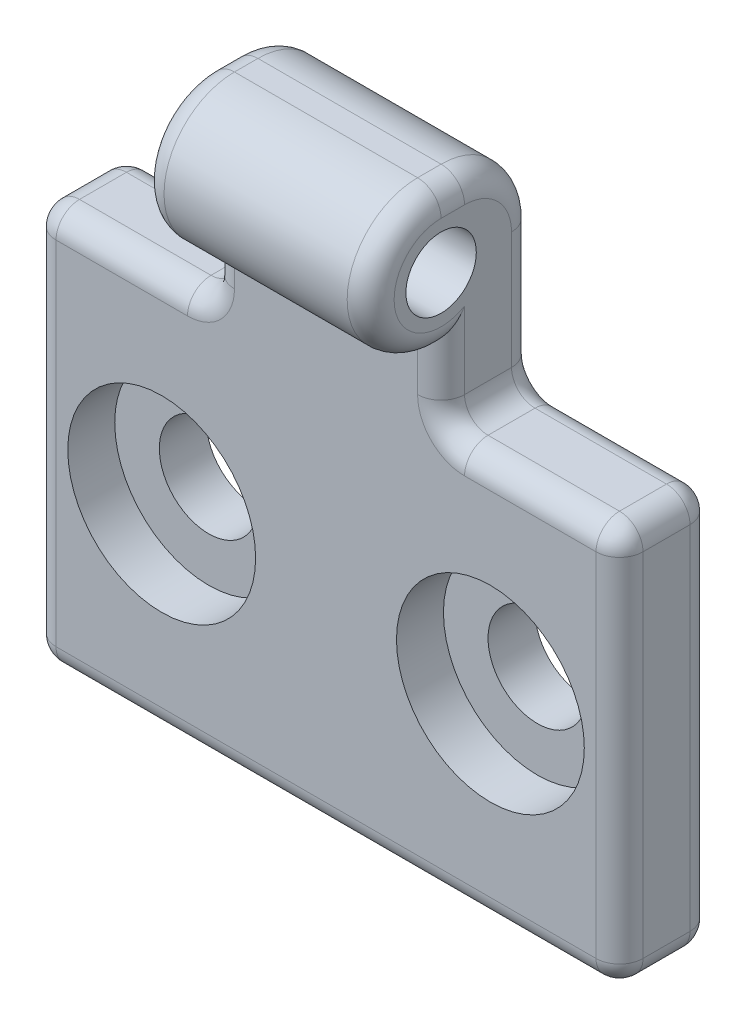
from build123d import *

# Parameters (mm, degrees)
ESQUISSE1_W                                       = 25
ESQUISSE1_H                                       = 26
BOSS_EXTRU_1_DEPTH                                = 4
BOSS_EXTRU_2_DEPTH                                = 25
ESQUISSE3_R                                       = 1.5
ENL_V_MAT_EXTRU_1_DEPTH                           = 25
ENL_V_MAT_EXTRU_2_DEPTH                           = 25
ENL_V_MAT_EXTRU_2_DEPTH_BACK                      = 25
ESQUISSE4_W                                       = 7.6
ESQUISSE4_H                                       = 9
CHAMBRAGE_POUR_VIS_SIX_PANS_CREUX_M41_D           = 4.2
CHAMBRAGE_POUR_VIS_SIX_PANS_CREUX_M41_CBORE_D     = 8
CHAMBRAGE_POUR_VIS_SIX_PANS_CREUX_M41_CBORE_DEPTH = 2
CONG_1_R                                          = 1


with BuildPart() as part:
    # Esquisse1 → Boss.-Extru.1 (new body)
    with BuildSketch(Plane.XY):
        with Locations((12.5, 13)):
            Rectangle(ESQUISSE1_W, ESQUISSE1_H)
    extrude(amount=BOSS_EXTRU_1_DEPTH)

    # Esquisse2 → Boss.-Extru.2 (add)
    with BuildSketch(Plane(origin=(25, 0, 0), x_dir=(0, 0, -1), z_dir=(1, 0, 0))):
        with BuildLine():
            Line((-4, 20), (-4, 26))
            ThreePointArc((-4, 26), (-7, 23), (-4, 20))
        make_face()
    extrude(amount=-BOSS_EXTRU_2_DEPTH)

    # Esquisse3 → Enlèv. mat.-Extru.1 (cut)
    with BuildSketch(Plane(origin=(25, 0, 0), x_dir=(0, 0, -1), z_dir=(1, 0, 0))):
        with BuildLine():
            ThreePointArc((-3, 26), (-0.878679656, 25.121320344), (0, 23))
            Line((0, 23), (0, 26))
            Line((0, 26), (-3, 26))
        make_face()
        with Locations((-4, 23)):
            Circle(ESQUISSE3_R)
    extrude(amount=-ENL_V_MAT_EXTRU_1_DEPTH, mode=Mode.SUBTRACT)

    # Esquisse4 → Enlèv. mat.-Extru.2 (cut, two sides: drawn at the far end of the back side and taken through both)
    with BuildSketch(Plane.XY.offset(4).offset(-ENL_V_MAT_EXTRU_2_DEPTH_BACK)):
        with Locations((3.8, 21.5)):
            Rectangle(ESQUISSE4_W, ESQUISSE4_H)
        with Locations((21.2, 21.5)):
            Rectangle(ESQUISSE4_W, ESQUISSE4_H)
    extrude(amount=ENL_V_MAT_EXTRU_2_DEPTH + ENL_V_MAT_EXTRU_2_DEPTH_BACK, mode=Mode.SUBTRACT)

    # Chambrage pour vis à six pans creux M41 (through all)
    with Locations(Plane(origin=(5.5, 8.51504076, 4), x_dir=(1, 0, 0), z_dir=(0, 0, 1))):
        with Locations((0, 0), (14, 0)):
            CounterBoreHole(CHAMBRAGE_POUR_VIS_SIX_PANS_CREUX_M41_D / 2, CHAMBRAGE_POUR_VIS_SIX_PANS_CREUX_M41_CBORE_D / 2, CHAMBRAGE_POUR_VIS_SIX_PANS_CREUX_M41_CBORE_DEPTH)

    # Congé1
    cong_1_edges = [part.edges().sort_by_distance(p)[0] for p in [
        (7.6, 23, 7),
        (7.6, 26, 3.5),
        (7.6, 25.121320344, 0.878679656),
        (7.6, 20, 0),
        (7.6, 18.5, 4),
        (17.4, 20, 0),
        (17.4, 25.121320344, 0.878679656),
        (17.4, 26, 3.5),
        (12.5, 0, 4),
        (12.5, 0, 0),
        (0, 8.5, 4),
        (0, 0, 2),
        (0, 8.5, 0),
        (3.8, 17, 0),
        (7.6, 17, 2),
        (3.8, 17, 4),
        (0, 17, 2),
        (25, 0, 2),
        (25, 8.5, 4),
        (25, 8.5, 0),
        (25, 17, 2),
        (21.2, 17, 4),
        (17.4, 17, 2),
        (21.2, 17, 0),
        (17.4, 18.5, 4),
        (17.4, 23, 7),
    ]]
    fillet(cong_1_edges, radius=CONG_1_R)


solid = part.part
